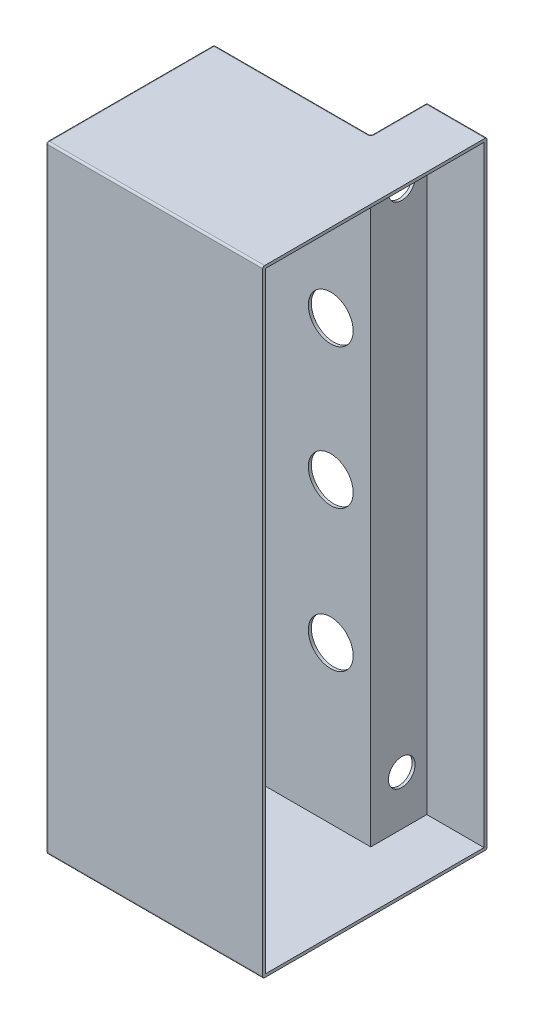
from build123d import *

# Parameters (mm, degrees)
EXTRUDE_1_DEPTH              = 165
SHELL_1_T                    = -0.8
SKETCH_2_R                   = 6
CUT_EXTRUDE_4_DEPTH          = 1
FILLET_1_R                   = 0.5
HOLE_WIZARD_9_32_0_28125_1_D = 7.14375


with BuildPart() as part:
    # 草图1 → 凸台-拉伸1 (new body)
    with BuildSketch(Plane(origin=(0, 0, 0), x_dir=(1, 0, 0), z_dir=(0, 1, 0))):
        Polygon((3, 5), (3, -55), (-55, -55), (-55, -10), (-13.1, -10), (-13.1, 5), align=None)
    extrude(amount=EXTRUDE_1_DEPTH)

    # 抽壳1
    shell_1_openings = [part.faces().sort_by_distance(p)[0] for p in [
        (3, 82.5, 25),
    ]]
    offset(amount=SHELL_1_T, openings=shell_1_openings, kind=Kind.INTERSECTION)

    # 草图2 → 切除-拉伸4 (cut)
    with BuildSketch(Plane(origin=(0, 0, 10), x_dir=(-1, 0, 0), z_dir=(0, 0, -1))):
        with Locations((23, 42.75)):
            Circle(SKETCH_2_R)
        with Locations((23, 118)):
            Circle(SKETCH_2_R)
        with Locations((23, 80.55)):
            Circle(SKETCH_2_R)
    extrude(amount=-CUT_EXTRUDE_4_DEPTH, mode=Mode.SUBTRACT)

    # 圆角1
    fillet_1_edges = [part.edges().sort_by_distance(p)[0] for p in [
        (-55, 82.5, 55),
        (-55, 82.5, 10),
        (-13.1, 82.5, 10),
        (-13.1, 82.5, -5),
        (-34.05, 165, 10),
        (-55, 165, 32.5),
        (-26, 165, 55),
        (-5.05, 165, -5),
        (-26, 0, 55),
        (-55, 0, 32.5),
        (-34.05, 0, 10),
        (-13.1, 0, 2.5),
        (-5.05, 0, -5),
        (-13.1, 165, 2.5),
    ]]
    fillet(fillet_1_edges, radius=FILLET_1_R)

    # 9/32 (0.28125) 直径孔1 (through all)
    with Locations(Plane.ZY.offset(13.1)):
        with Locations((2.5, 150), (2.5, 14)):
            Hole(HOLE_WIZARD_9_32_0_28125_1_D / 2)


solid = part.part
